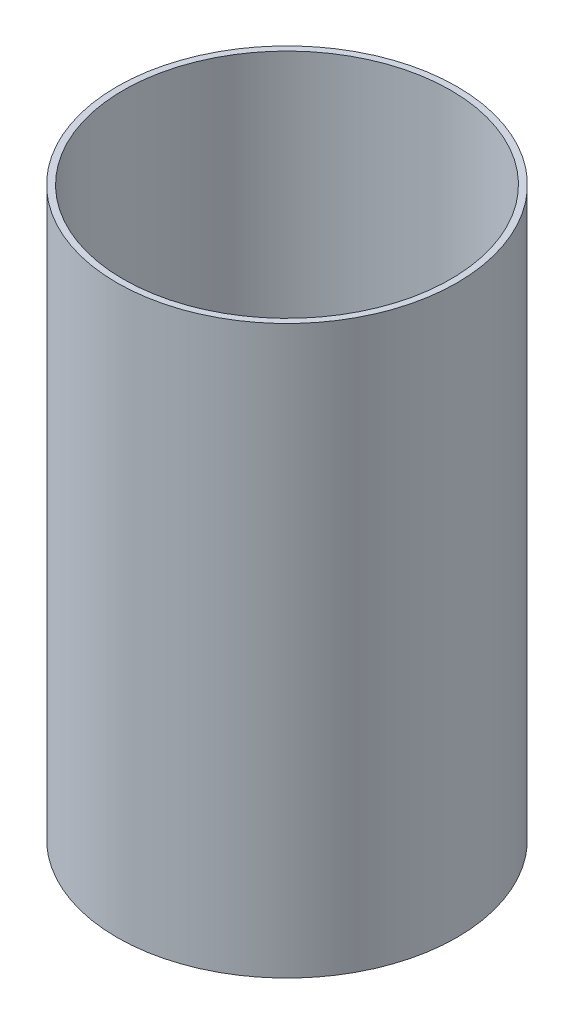
from build123d import *

# Parameters (mm, degrees)
COUPLER_PROFILE_R   = 76.1746
COUPLER_PROFILE_R_2 = 73.3425
COUPLER_BODY_DEPTH  = 254


with BuildPart() as part:
    # Coupler Profile → Coupler Body (new body)
    with BuildSketch(Plane(origin=(0, 0, 0), x_dir=(1, 0, 0), z_dir=(0, 1, 0))):
        Circle(COUPLER_PROFILE_R)
        Circle(COUPLER_PROFILE_R_2, mode=Mode.SUBTRACT)
    extrude(amount=COUPLER_BODY_DEPTH)


solid = part.part
